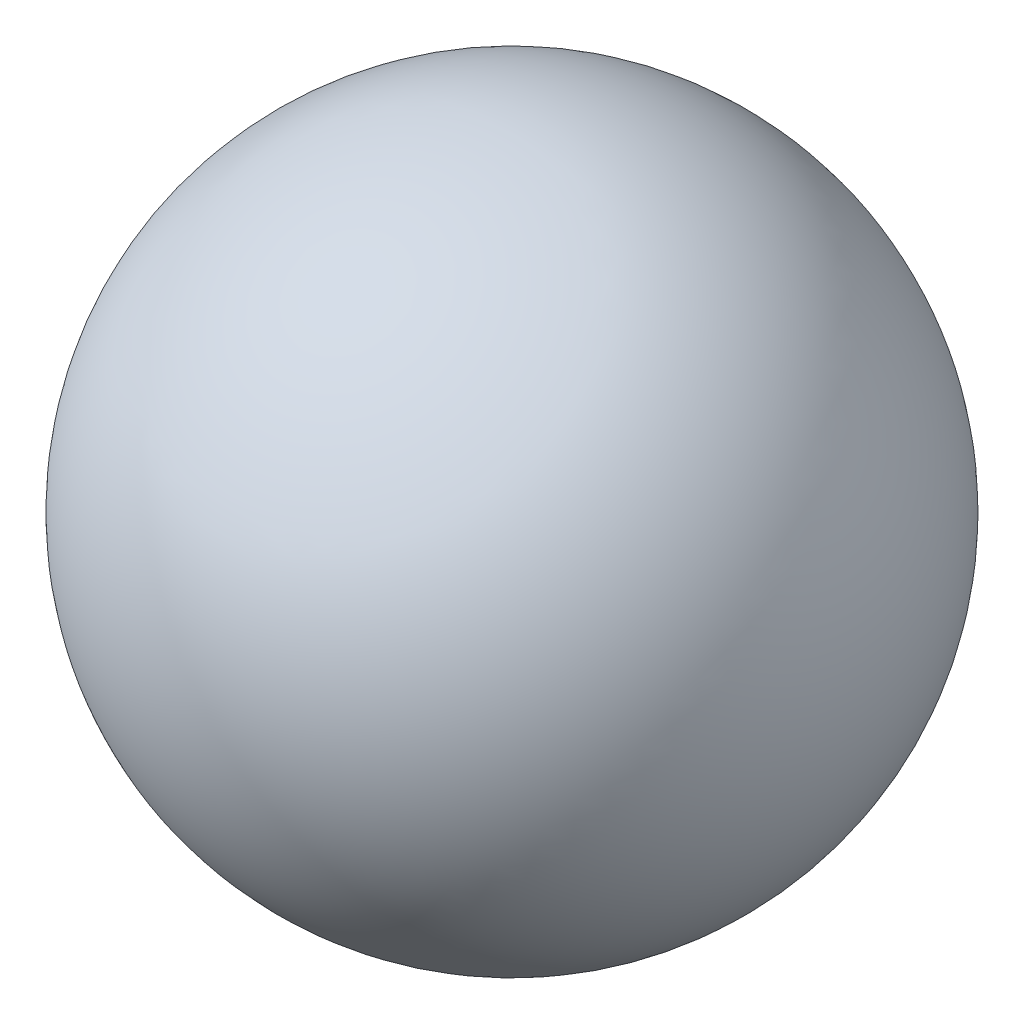
from build123d import *

# Parameters (mm, degrees)
M3X0_5_TAPPED_HOLE1_D     = 2.5
M3X0_5_TAPPED_HOLE1_DEPTH = 6
M3X0_5_TAPPED_HOLE1_TIP   = 0.751075774


with BuildPart() as part:
    # Sketch2 → Revolve1 (revolve)
    with BuildSketch(Plane(origin=(0, 0, 0), x_dir=(1, 0, 0), z_dir=(0, 1, 0))):
        with BuildLine():
            Line((1.936491673, 7.5), (0, 7.5))
            Line((0, 7.5), (0, 0))
            ThreePointArc((0, 0), (3.872983346, 3), (1.936491673, 7.5))
        make_face()
    revolve(axis=Axis((0, 0, -7.5), (0, 0, 1)))

    # M3x0.5 Tapped Hole1
    with Locations(Plane(origin=(0, 0, -7.5), x_dir=(-1, 0, 0), z_dir=(0, 0, -1))):
        with Locations((0, 0)):
            Hole(M3X0_5_TAPPED_HOLE1_D / 2, depth=M3X0_5_TAPPED_HOLE1_DEPTH)
            with Locations((0, 0, -(M3X0_5_TAPPED_HOLE1_DEPTH + M3X0_5_TAPPED_HOLE1_TIP / 2))):  # 118° drill point
                Cone(0, M3X0_5_TAPPED_HOLE1_D / 2, M3X0_5_TAPPED_HOLE1_TIP, mode=Mode.SUBTRACT)


solid = part.part
